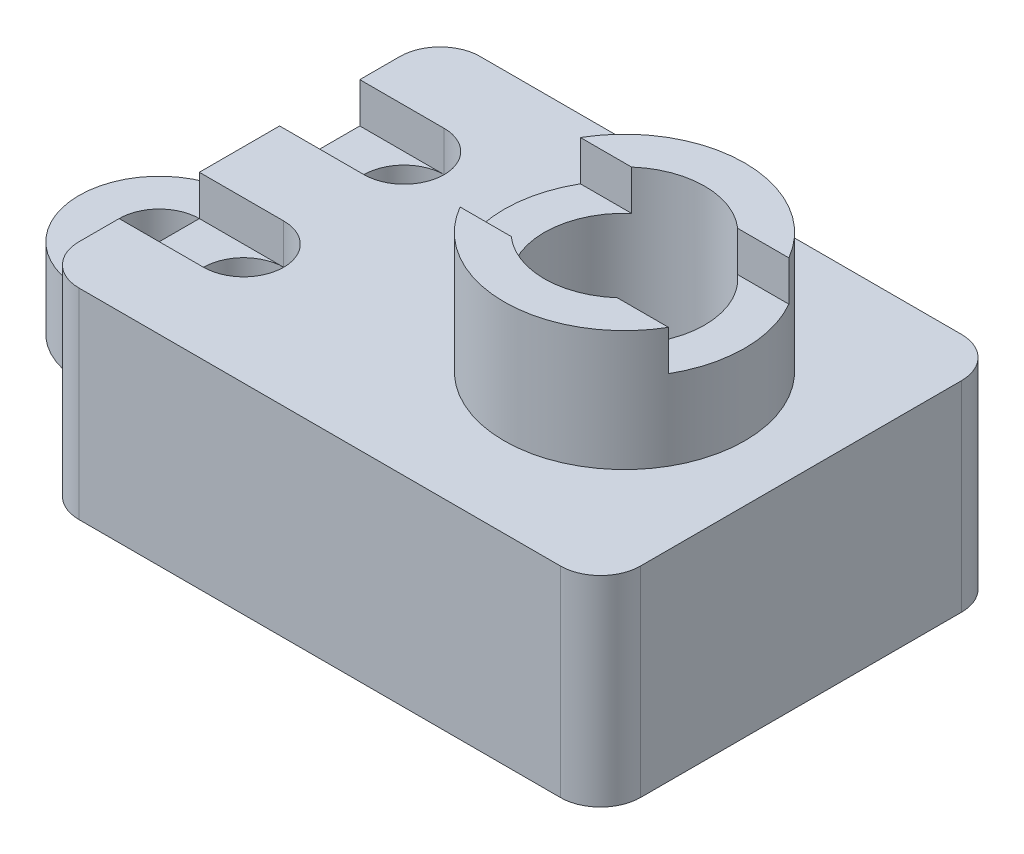
from build123d import *

# Parameters (mm, degrees)
SKETCH1_R           = 1
BOSS_EXTRUDE1_DEPTH = 5
SKETCH3_W           = 12
SKETCH3_H           = 8
CUT_EXTRUDE1_DEPTH  = 3
SKETCH4_R           = 3
SKETCH4_R_2         = 2
BOSS_EXTRUDE2_DEPTH = 3
SKETCH5_W           = 3
SKETCH5_H           = 1
CUT_EXTRUDE2_DEPTH  = 17
SKETCH6_R           = 2
SKETCH6_R_2         = 1
SKETCH6_W           = 7.064198251
SKETCH6_H           = 8.717344461
CUT_EXTRUDE3_DEPTH  = 6
CUT_EXTRUDE4_DEPTH  = 1


with BuildPart() as part:
    # Sketch1 → Boss-Extrude1 (new body)
    with BuildSketch(Plane(origin=(0, 0, 0), x_dir=(1, 0, 0), z_dir=(0, 1, 0))):
        with BuildLine():
            Line((1, 2), (0, 2))
            ThreePointArc((0, 2), (-2, 0), (0, -2))
            Line((0, -2), (1, -2))
            ThreePointArc((1, -2), (1.684527719, -2.270177533), (2, -2.935046948))
            Line((2, -2.935046948), (2, -4))
            ThreePointArc((2, -4), (2.292893219, -4.707106781), (3, -5))
            Line((3, -5), (15, -5))
            ThreePointArc((15, -5), (15.707106781, -4.707106781), (16, -4))
            Line((16, -4), (16, 4))
            ThreePointArc((16, 4), (15.707106781, 4.707106781), (15, 5))
            Line((15, 5), (3, 5))
            ThreePointArc((3, 5), (2.292893219, 4.707106781), (2, 4))
            Line((2, 4), (2, 2.932864189))
            ThreePointArc((2, 2.932864189), (1.684390871, 2.268771092), (1, 2))
        make_face()
        Circle(SKETCH1_R, mode=Mode.SUBTRACT)
    extrude(amount=BOSS_EXTRUDE1_DEPTH)

    # Sketch3 → Cut-Extrude1 (cut)
    with BuildSketch(Plane.XZ):
        with Locations((9, 0)):
            Rectangle(SKETCH3_W, SKETCH3_H)
    extrude(amount=-CUT_EXTRUDE1_DEPTH, mode=Mode.SUBTRACT)

    # Sketch4 → Boss-Extrude2 (add)
    with BuildSketch(Plane(origin=(0, 5, 0), x_dir=(1, 0, 0), z_dir=(0, 1, 0))):
        with Locations((11.597924937, 0)):
            Circle(SKETCH4_R)
        with Locations((11.597924937, 0)):
            Circle(SKETCH4_R_2, mode=Mode.SUBTRACT)
    extrude(amount=BOSS_EXTRUDE2_DEPTH)

    # Sketch5 → Cut-Extrude2 (cut)
    with BuildSketch(Plane.ZY.offset(-2)):
        with Locations((0, 7.5)):
            Rectangle(SKETCH5_W, SKETCH5_H)
    extrude(amount=-CUT_EXTRUDE2_DEPTH, mode=Mode.SUBTRACT)

    # Sketch6 → Cut-Extrude3 (cut)
    with BuildSketch(Plane(origin=(0, 8, 0), x_dir=(1, 0, 0), z_dir=(0, 1, 0))):
        with Locations((11.597924937, 0)):
            Circle(SKETCH6_R)
        with Locations((4.102933475, -2)):
            Circle(SKETCH6_R_2)
        with Locations((4.102933475, 2)):
            Circle(SKETCH6_R_2)
        with Locations((-1.532099126, -1.425808042)):
            Rectangle(SKETCH6_W, SKETCH6_H)
    extrude(amount=-CUT_EXTRUDE3_DEPTH, mode=Mode.SUBTRACT)

    # Sketch7 → Cut-Extrude4 (cut)
    with BuildSketch(Plane(origin=(0, 5, 0), x_dir=(1, 0, 0), z_dir=(0, 1, 0))):
        with BuildLine():
            Line((4.102933475, -3), (0.252638608, -3))
            ThreePointArc((0.252638608, -3), (-0.747361392, -2), (0.252638608, -1))
            Line((0.252638608, -1), (4.102933475, -1))
            ThreePointArc((4.102933475, -1), (5.102933475, -2), (4.102933475, -3))
        make_face()
        with BuildLine():
            Line((4.102933475, 1), (0.944196424, 1))
            ThreePointArc((0.944196424, 1), (-0.055803576, 2), (0.944196424, 3))
            Line((0.944196424, 3), (4.102933475, 3))
            ThreePointArc((4.102933475, 3), (5.102933475, 2), (4.102933475, 1))
        make_face()
    extrude(amount=-CUT_EXTRUDE4_DEPTH, mode=Mode.SUBTRACT)


solid = part.part
